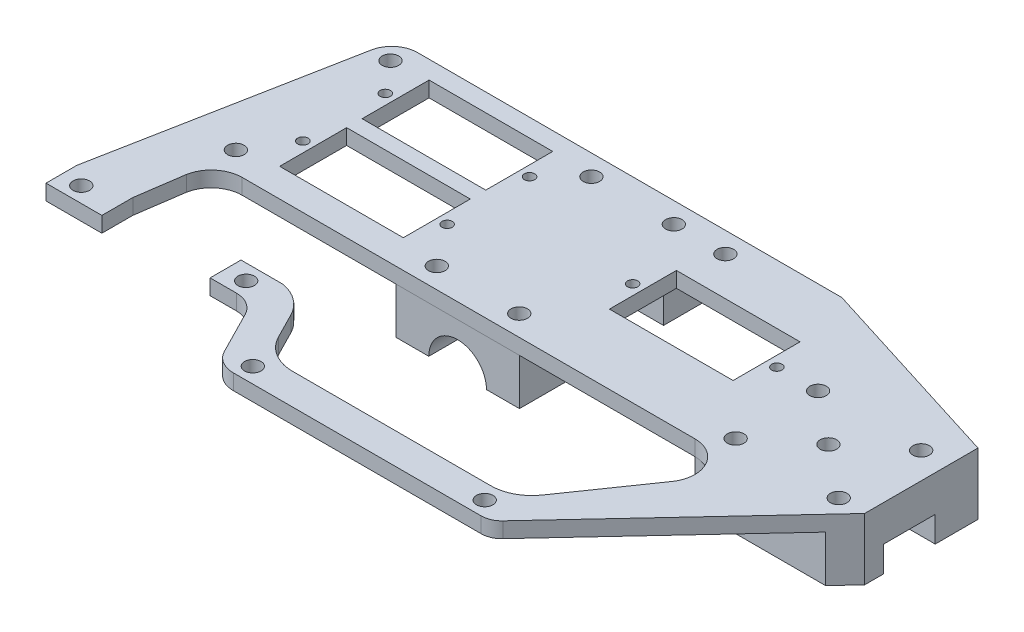
from build123d import *

# Parameters (mm, degrees)
SKETCH_1_R          = 1.6
SKETCH_1_R_2        = 1
SKETCH_1_W          = 24
SKETCH_1_H          = 13
EXTRUDE_1_DEPTH     = 3
SKETCH_2_R          = 1.6
SKETCH_2_W          = 24
SKETCH_2_H          = 10
EXTRUDE_2_DEPTH     = 9
SKETCH_3_W          = 10
SKETCH_3_H          = 10
CUT_EXTRUDE_1_DEPTH = 20
SKETCH_4_R          = 4
CUT_EXTRUDE_2_DEPTH = 72.704206567
SKETCH_6_R          = 5.6
CUT_EXTRUDE_3_DEPTH = 5
SKETCH_7_R          = 5.6
CUT_EXTRUDE_4_DEPTH = 6
FILLET_5_R          = 5
FILLET_6_R          = 5
SKETCH_8_W          = 21
SKETCH_8_H          = 6
CUT_EXTRUDE_5_DEPTH = 13


with BuildPart() as part:
    # Эскиз1 → Бобышка-Вытянуть1 (new body)
    with BuildSketch(Plane(origin=(0, 0, 0), x_dir=(1, 0, 0), z_dir=(0, 1, 0))):
        with BuildLine():
            Line((-59.846473334, -34), (-49.887758312, 18))
            Line((-49.887758312, 18), (36.612736258, 18))
            Line((36.612736258, 18), (75.112241688, 5.920216985))
            Line((75.112241688, 5.920216985), (75.112241688, -16.079783015))
            Line((75.112241688, -16.079783015), (41.245672077, -52.430849732))
            ThreePointArc((41.245672077, -52.430849732), (39.914841322, -53.372078747), (38.318998701, -53.704206567))
            Line((38.318998701, -53.704206567), (-9.799827382, -53.704206567))
            ThreePointArc((-9.799827382, -53.704206567), (-12.412320205, -52.967407389), (-14.254860003, -50.974159066))
            Line((-14.254860003, -50.974159066), (-19.846473334, -40))
            Line((-19.846473334, -40), (-59.846473334, -40))
            Line((-59.846473334, -40), (-59.846473334, -34))
        make_face()
        with Locations((-8, 14)):
            Circle(SKETCH_1_R, mode=Mode.SUBTRACT)
        with Locations((8, 14)):
            Circle(SKETCH_1_R, mode=Mode.SUBTRACT)
        with Locations((-8, -16)):
            Circle(SKETCH_1_R, mode=Mode.SUBTRACT)
        with Locations((8, -16)):
            Circle(SKETCH_1_R, mode=Mode.SUBTRACT)
        with Locations((-47, 14)):
            Circle(SKETCH_1_R, mode=Mode.SUBTRACT)
        with Locations((70, 0)):
            Circle(SKETCH_1_R, mode=Mode.SUBTRACT)
        with Locations((50, 0)):
            Circle(SKETCH_1_R, mode=Mode.SUBTRACT)
        with Locations((18, 14)):
            Circle(SKETCH_1_R, mode=Mode.SUBTRACT)
        with Locations((-47, -16)):
            Circle(SKETCH_1_R, mode=Mode.SUBTRACT)
        with Locations((-56, -37)):
            Circle(SKETCH_1_R, mode=Mode.SUBTRACT)
        with Locations((-24, -37)):
            Circle(SKETCH_1_R, mode=Mode.SUBTRACT)
        with Locations((50, -16)):
            Circle(SKETCH_1_R, mode=Mode.SUBTRACT)
        with Locations((70, -16)):
            Circle(SKETCH_1_R, mode=Mode.SUBTRACT)
        with Locations((-9, -50.704206567)):
            Circle(SKETCH_1_R, mode=Mode.SUBTRACT)
        with Locations((36, -50.704206567)):
            Circle(SKETCH_1_R, mode=Mode.SUBTRACT)
        with Locations((60, -8)):
            Circle(SKETCH_1_R, mode=Mode.SUBTRACT)
        with Locations((-42, -8)):
            Circle(SKETCH_1_R_2, mode=Mode.SUBTRACT)
        with Locations((-14, -8)):
            Circle(SKETCH_1_R_2, mode=Mode.SUBTRACT)
        with Locations((-42, 8)):
            Circle(SKETCH_1_R_2, mode=Mode.SUBTRACT)
        with Locations((-14, 8)):
            Circle(SKETCH_1_R_2, mode=Mode.SUBTRACT)
        with Locations((14, 0)):
            Circle(SKETCH_1_R_2, mode=Mode.SUBTRACT)
        with Locations((42, 0)):
            Circle(SKETCH_1_R_2, mode=Mode.SUBTRACT)
        with Locations((28, 0)):
            Rectangle(SKETCH_1_W, SKETCH_1_H, mode=Mode.SUBTRACT)
        with Locations((-28, 8)):
            Rectangle(SKETCH_1_W, SKETCH_1_H, mode=Mode.SUBTRACT)
        with Locations((-28, -8)):
            Rectangle(SKETCH_1_W, SKETCH_1_H, mode=Mode.SUBTRACT)
        with BuildLine():
            Line((-47.677053254, -24.900709984), (-49.000145857, -34))
            Line((-49.000145857, -34), (-22.297676486, -34))
            Line((-22.297676486, -34), (-19.846473334, -34))
            ThreePointArc((-19.846473334, -34), (-16.425778662, -35.467187694), (-13.988679802, -38.280431537))
            Line((-13.988679802, -38.280431537), (-11.413907263, -43.333707171))
            ThreePointArc((-11.413907263, -43.333707171), (-8.465843587, -46.522904488), (-4.28585507, -47.701783173))
            Line((-4.28585507, -47.701783173), (34.165827616, -47.701783173))
            ThreePointArc((34.165827616, -47.701783173), (37.877016972, -46.788889321), (40.741225842, -44.258551563))
            Line((40.741225842, -44.258551563), (51.02606102, -29.417576293))
            ThreePointArc((51.02606102, -29.417576293), (51.409841961, -23.216607983), (46.09451235, -20))
            Line((46.09451235, -20), (-41.778616049, -20))
            ThreePointArc((-41.778616049, -20), (-45.612951708, -21.385038456), (-47.677053254, -24.900709984))
        make_face(mode=Mode.SUBTRACT)
    extrude(amount=EXTRUDE_1_DEPTH)

    # Эскиз2 → Бобышка-Вытянуть2 (add)
    with BuildSketch(Plane(origin=(0, 0, 0), x_dir=(1, 0, 0), z_dir=(0, 1, 0))):
        Polygon((46.101706289, 15.022696844), (46.09451235, -20), (71.459960933, -20), (75.112241688, -16.079783015), (75.112241688, 5.920216985), align=None)
        with Locations((50, 0)):
            Circle(SKETCH_2_R, mode=Mode.SUBTRACT)
        with Locations((70, 0)):
            Circle(SKETCH_2_R, mode=Mode.SUBTRACT)
        with Locations((70, -16)):
            Circle(SKETCH_2_R, mode=Mode.SUBTRACT)
        with Locations((50, -16)):
            Circle(SKETCH_2_R, mode=Mode.SUBTRACT)
        with Locations((60, -8)):
            Circle(SKETCH_2_R, mode=Mode.SUBTRACT)
        with Locations((0, 13)):
            Rectangle(SKETCH_2_W, SKETCH_2_H)
        with Locations((-8, 14)):
            Circle(SKETCH_2_R, mode=Mode.SUBTRACT)
        with Locations((8, 14)):
            Circle(SKETCH_2_R, mode=Mode.SUBTRACT)
        with Locations((0, -14.961092538)):
            Rectangle(SKETCH_2_W, SKETCH_2_H)
        with Locations((-8, -16)):
            Circle(SKETCH_2_R, mode=Mode.SUBTRACT)
        with Locations((8, -16)):
            Circle(SKETCH_2_R, mode=Mode.SUBTRACT)
    extrude(amount=-EXTRUDE_2_DEPTH)

    # Эскиз3 → Вырез-Вытянуть1 (cut)
    with BuildSketch(Plane(origin=(75.112241688, 0, 0), x_dir=(0, 0, -1), z_dir=(1, 0, 0))):
        with Locations((-7.384625177, -9)):
            Rectangle(SKETCH_3_W, SKETCH_3_H)
    extrude(amount=-CUT_EXTRUDE_1_DEPTH, mode=Mode.SUBTRACT)

    # Эскиз4 → Вырез-Вытянуть2 (cut, through all)
    with BuildSketch(Plane(origin=(0, 0, -18), x_dir=(-1, 0, 0), z_dir=(0, 0, -1))):
        with Locations((0, -9)):
            Circle(SKETCH_4_R)
    extrude(amount=-CUT_EXTRUDE_2_DEPTH, mode=Mode.SUBTRACT)

    # Эскиз6 → Вырез-Вытянуть3 (cut)
    with BuildSketch(Plane(origin=(0, 0, -18), x_dir=(-1, 0, 0), z_dir=(0, 0, -1))):
        with Locations((0, -9)):
            Circle(SKETCH_6_R)
    extrude(amount=-CUT_EXTRUDE_3_DEPTH, mode=Mode.SUBTRACT)

    # Эскиз7 → Вырез-Вытянуть4 (cut)
    with BuildSketch(Plane.XY.offset(19.961092538)):
        with Locations((0, -9)):
            Circle(SKETCH_7_R)
    extrude(amount=-CUT_EXTRUDE_4_DEPTH, mode=Mode.SUBTRACT)

    # Скругление5
    fillet_5_edges = [part.edges().sort_by_distance(p)[0] for p in [
        (-49.887758312, 1.5, -18),
    ]]
    fillet(fillet_5_edges, radius=FILLET_5_R)

    # Скругление6
    fillet_6_edges = [part.edges().sort_by_distance(p)[0] for p in [
        (-19.846473334, 1.5, 40),
    ]]
    fillet(fillet_6_edges, radius=FILLET_6_R)

    # Эскиз8 → Вырез-Вытянуть5 (cut, through all)
    with BuildSketch(Plane(origin=(0, 3, 0), x_dir=(1, 0, 0), z_dir=(0, 1, 0))):
        with Locations((-38.500145857, -37)):
            Rectangle(SKETCH_8_W, SKETCH_8_H)
    extrude(amount=-CUT_EXTRUDE_5_DEPTH, mode=Mode.SUBTRACT)


solid = part.part
